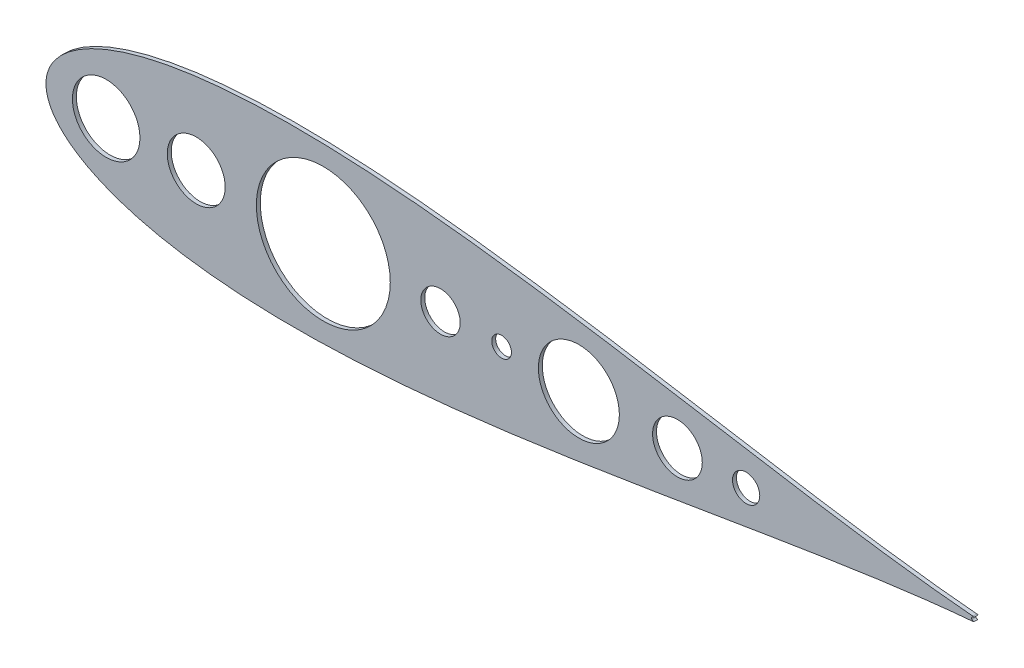
from build123d import *

# Parameters (mm, degrees)
SKETCH2_R           = 18.669
SKETCH2_R_2         = 12.7
SKETCH2_R_3         = 6.35
SKETCH2_R_4         = 16.028770825
SKETCH2_R_5         = 8.77991455
SKETCH2_R_6         = 21.7634135
SKETCH2_R_7         = 26.10316595
SKETCH2_R_8         = 43.16695288
BOSS_EXTRUDE1_DEPTH = 2.54


with BuildPart() as part:
    # Sketch2 → Boss-Extrude1 (new body)
    with BuildSketch(Plane.XY):
        with BuildLine():
            ThreePointArc((890.816164168, 510.477369134), (891.200246589, 510.561868165), (891.54839493, 510.744767385))
            ThreePointArc((891.54839493, 510.744767385), (889.987641806, 511.948825855), (891.548941561, 513.152175425))
            ThreePointArc((891.548941561, 513.152175425), (891.200561465, 513.335347828), (890.816164168, 513.419961883))
            add(Edge.make_bspline(
                [(890.816164168, 513.419961883), (890.334929222, 513.459981198), (886.708241771, 513.76546367), (879.565924572, 514.42561402), (868.964209832, 515.528471419), (857.209813649, 516.881784466), (844.346922273, 518.493665975), (830.435546641, 520.365757128), (815.535846116, 522.493860762), (799.712341782, 524.86698431), (783.032227934, 527.468245812), (765.56538449, 530.274419358), (747.383994901, 533.25652103), (728.562336326, 536.380171047), (709.176538958, 539.605942423), (689.304458457, 542.890066943), (669.025547897, 546.184960618), (648.420790788, 549.440003688), (627.572657185, 552.602222866), (606.565100392, 555.617231646), (585.483547136, 558.429920334), (564.414918297, 560.985438326), (543.447643352, 563.229982452), (522.671673877, 565.111747072), (502.178474967, 566.581679788), (482.06102345, 567.594398692), (462.413787666, 568.109046223), (443.332695327, 568.089939543), (424.915165793, 567.506768628), (407.260111586, 566.336700548), (390.46822582, 564.562768168), (374.642141664, 562.176975246), (359.88739169, 559.178484874), (346.313124377, 555.577330562), (334.03409686, 551.394617799), (323.172804405, 546.667615258), (313.861144192, 541.458918976), (306.23822821, 535.87422877), (300.432417668, 530.095948609), (296.501791132, 524.429595122), (294.309964234, 519.317417686), (293.424863104, 515.216496363), (293.223273347, 511.948665511), (293.424863104, 508.680834659), (294.309964234, 504.579913337), (296.501791132, 499.4677359), (300.432417668, 493.801382414), (306.23822821, 488.023102253), (313.861144192, 482.438412046), (323.172804405, 477.229715765), (334.03409686, 472.502713223), (346.313124377, 468.32000046), (359.88739169, 464.718846148), (374.642141664, 461.720355776), (390.46822582, 459.334562854), (407.260111586, 457.560630475), (424.915165793, 456.390562395), (443.332695327, 455.80739148), (462.413787666, 455.788284799), (482.06102345, 456.30293233), (502.178474967, 457.315651235), (522.671673877, 458.78558395), (543.447643352, 460.66734857), (564.414918297, 462.911892697), (585.483547136, 465.467410689), (606.565100392, 468.280099376), (627.572657185, 471.295108156), (648.420790788, 474.457327335), (669.025547897, 477.712370404), (689.304458457, 481.007264079), (709.176538958, 484.2913886), (728.562336326, 487.517159975), (747.383994901, 490.640809992), (765.56538449, 493.622911665), (783.032227934, 496.429085211), (799.712341782, 499.030346713), (815.535846116, 501.40347026), (830.435546641, 503.531573895), (844.346922273, 505.403665048), (857.209813649, 507.015546557), (868.964209832, 508.368859604), (879.565924572, 509.471717003), (886.708241771, 510.131867352), (890.334929222, 510.437349825), (890.816164168, 510.477369134)],
                knots=[0.020157042, 0.020157042, 0.020157042, 0.020157042, 0.021270888, 0.028552555, 0.036780684, 0.045920102, 0.055931764, 0.066772884, 0.07839713, 0.090754827, 0.103793165, 0.117456432, 0.131686226, 0.146421738, 0.161599998, 0.177156133, 0.193023668, 0.209134786, 0.225420633, 0.241811602, 0.258237647, 0.274628557, 0.290914287, 0.307025229, 0.322892517, 0.338448342, 0.353626207, 0.368361232, 0.382590428, 0.396252961, 0.409290412, 0.42164701, 0.433269881, 0.444109249, 0.45411864, 0.463255055, 0.471479114, 0.478755289, 0.485052318, 0.490344026, 0.494609833, 0.497833231, 0.5, 0.502166769, 0.505390167, 0.509655974, 0.514947682, 0.521244711, 0.528520886, 0.536744945, 0.54588136, 0.555890751, 0.566730119, 0.57835299, 0.590709588, 0.603747039, 0.617409572, 0.631638768, 0.646373793, 0.661551658, 0.677107483, 0.692974771, 0.709085713, 0.725371443, 0.741762353, 0.758188398, 0.774579367, 0.790865214, 0.806976332, 0.822843867, 0.838400002, 0.853578262, 0.868313774, 0.882543568, 0.896206835, 0.909245173, 0.92160287, 0.933227116, 0.944068236, 0.954079898, 0.963219316, 0.971447445, 0.978729112, 0.979842958, 0.979842958, 0.979842958, 0.979842958], degree=3))
        make_face()
        with Locations((390.131274336, 511.948665509)):
            Circle(SKETCH2_R, mode=Mode.SUBTRACT)
        with Locations((547.611274336, 511.948665509)):
            Circle(SKETCH2_R_2, mode=Mode.SUBTRACT)
        with Locations((586.981274336, 511.948665509)):
            Circle(SKETCH2_R_3, mode=Mode.SUBTRACT)
        with Locations((700.323442246, 511.948665509)):
            Circle(SKETCH2_R_4, mode=Mode.SUBTRACT)
        with Locations((744.61753791, 511.948665509)):
            Circle(SKETCH2_R_5, mode=Mode.SUBTRACT)
        with Locations((332.073077219, 511.948665509)):
            Circle(SKETCH2_R_6, mode=Mode.SUBTRACT)
        with Locations((636.787882815, 511.948665509)):
            Circle(SKETCH2_R_7, mode=Mode.SUBTRACT)
        with Locations((472.050636064, 511.948665509)):
            Circle(SKETCH2_R_8, mode=Mode.SUBTRACT)
    extrude(amount=BOSS_EXTRUDE1_DEPTH)


solid = part.part
